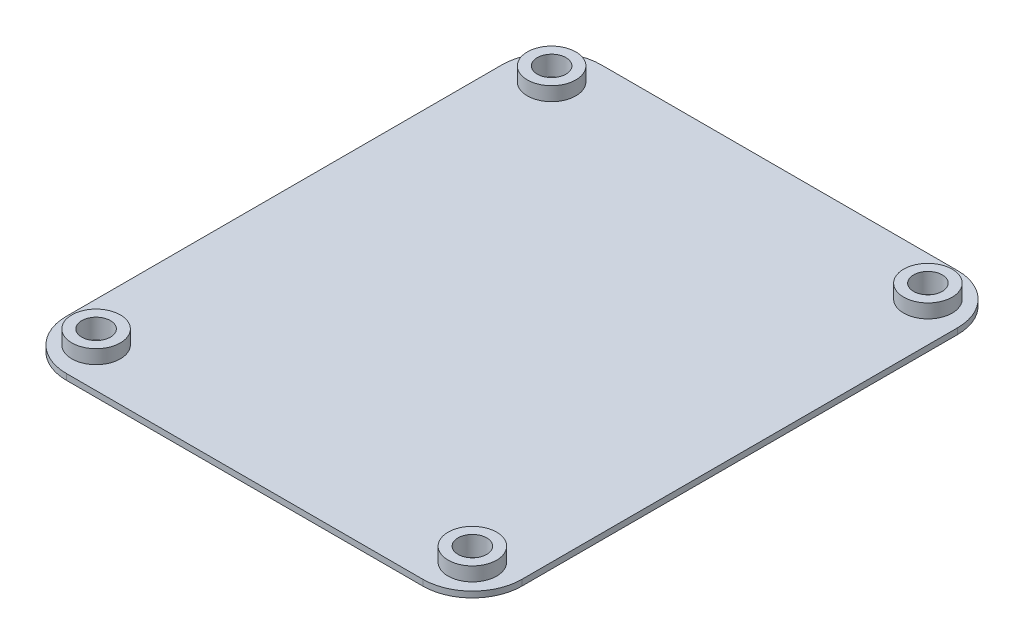
from build123d import *

# Parameters (mm, degrees)
SKETCH1_W           = 46
SKETCH1_H           = 54
SKETCH1_R           = 1.45
BOSS_EXTRUDE1_DEPTH = 0.6
SKETCH1_3_R         = 2.45
SKETCH1_3_R_2       = 1.45
BOSS_EXTRUDE2_DEPTH = 2
FILLET1_R           = 5


with BuildPart() as part:
    # Sketch1 → Boss-Extrude1 (new body)
    with BuildSketch(Plane(origin=(0, 0, 0), x_dir=(1, 0, 0), z_dir=(0, 1, 0))):
        Rectangle(SKETCH1_W, SKETCH1_H)
        with Locations((-19, -23)):
            Circle(SKETCH1_R, mode=Mode.SUBTRACT)
        with Locations((19, -23)):
            Circle(SKETCH1_R, mode=Mode.SUBTRACT)
        with Locations((-19, 23)):
            Circle(SKETCH1_R, mode=Mode.SUBTRACT)
        with Locations((19, 23)):
            Circle(SKETCH1_R, mode=Mode.SUBTRACT)
    extrude(amount=BOSS_EXTRUDE1_DEPTH)

    # Sketch1_3 → Boss-Extrude2 (add)
    # profile 1 of 4: a face of its own
    with BuildSketch(Plane(origin=(0, 0, 0), x_dir=(1, 0, 0), z_dir=(0, 1, 0))):
        with Locations((-19, 23)):
            Circle(SKETCH1_3_R)
        with Locations((-19, 23)):
            Circle(SKETCH1_3_R_2, mode=Mode.SUBTRACT)
    # profile 2 of 4: a face of its own
    with BuildSketch(Plane(origin=(0, 0, 0), x_dir=(1, 0, 0), z_dir=(0, 1, 0))):
        with Locations((19, 23)):
            Circle(SKETCH1_3_R)
        with Locations((19, 23)):
            Circle(SKETCH1_3_R_2, mode=Mode.SUBTRACT)
    # profile 3 of 4: a face of its own
    with BuildSketch(Plane(origin=(0, 0, 0), x_dir=(1, 0, 0), z_dir=(0, 1, 0))):
        with Locations((-19, -23)):
            Circle(SKETCH1_3_R)
        with Locations((-19, -23)):
            Circle(SKETCH1_3_R_2, mode=Mode.SUBTRACT)
    # profile 4 of 4: a face of its own
    with BuildSketch(Plane(origin=(0, 0, 0), x_dir=(1, 0, 0), z_dir=(0, 1, 0))):
        with Locations((19, -23)):
            Circle(SKETCH1_3_R)
        with Locations((19, -23)):
            Circle(SKETCH1_3_R_2, mode=Mode.SUBTRACT)
    extrude(amount=BOSS_EXTRUDE2_DEPTH)

    # Fillet1
    fillet1_edges = [part.edges().sort_by_distance(p)[0] for p in [
        (-23, 0.3, -27),
        (23, 0.3, -27),
        (-23, 0.3, 27),
        (23, 0.3, 27),
    ]]
    fillet(fillet1_edges, radius=FILLET1_R)


solid = part.part
